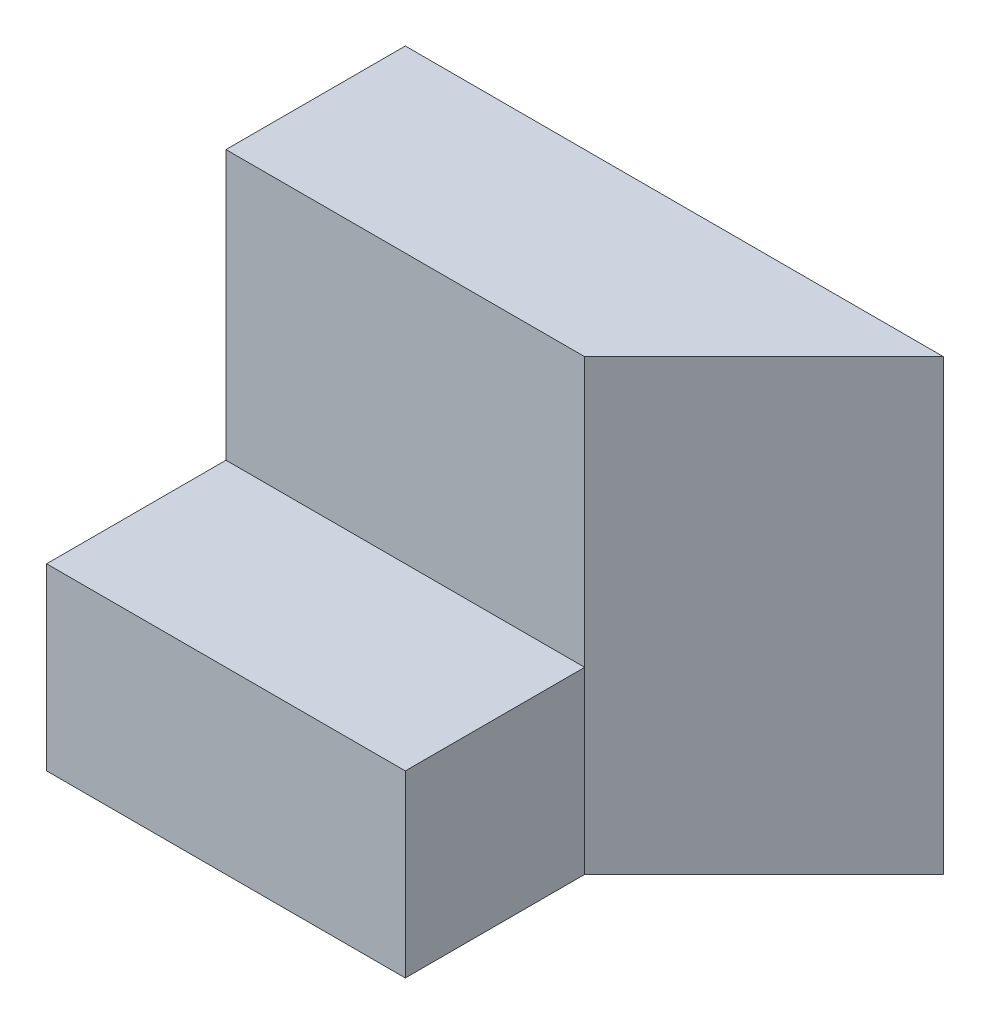
from build123d import *

# Parameters (mm, degrees)
BOSS_EXTRUDE1_DEPTH = 5
SKETCH4_W           = 2
SKETCH4_H           = 3
CUT_EXTRUDE3_DEPTH  = 15


with BuildPart() as part:
    # Sketch1 → Boss-Extrude1 (new body)
    with BuildSketch(Plane(origin=(0, 0, 0), x_dir=(1, 0, 0), z_dir=(0, 1, 0))):
        Polygon((4, 2), (4, 0), (0, 0), (0, 2), (0, 4), (6, 4), align=None)
    extrude(amount=BOSS_EXTRUDE1_DEPTH)

    # Sketch4 → Cut-Extrude3 (cut)
    with BuildSketch(Plane.ZY):
        with Locations((-1, 3.5)):
            Rectangle(SKETCH4_W, SKETCH4_H)
    extrude(amount=-CUT_EXTRUDE3_DEPTH, mode=Mode.SUBTRACT)


solid = part.part
